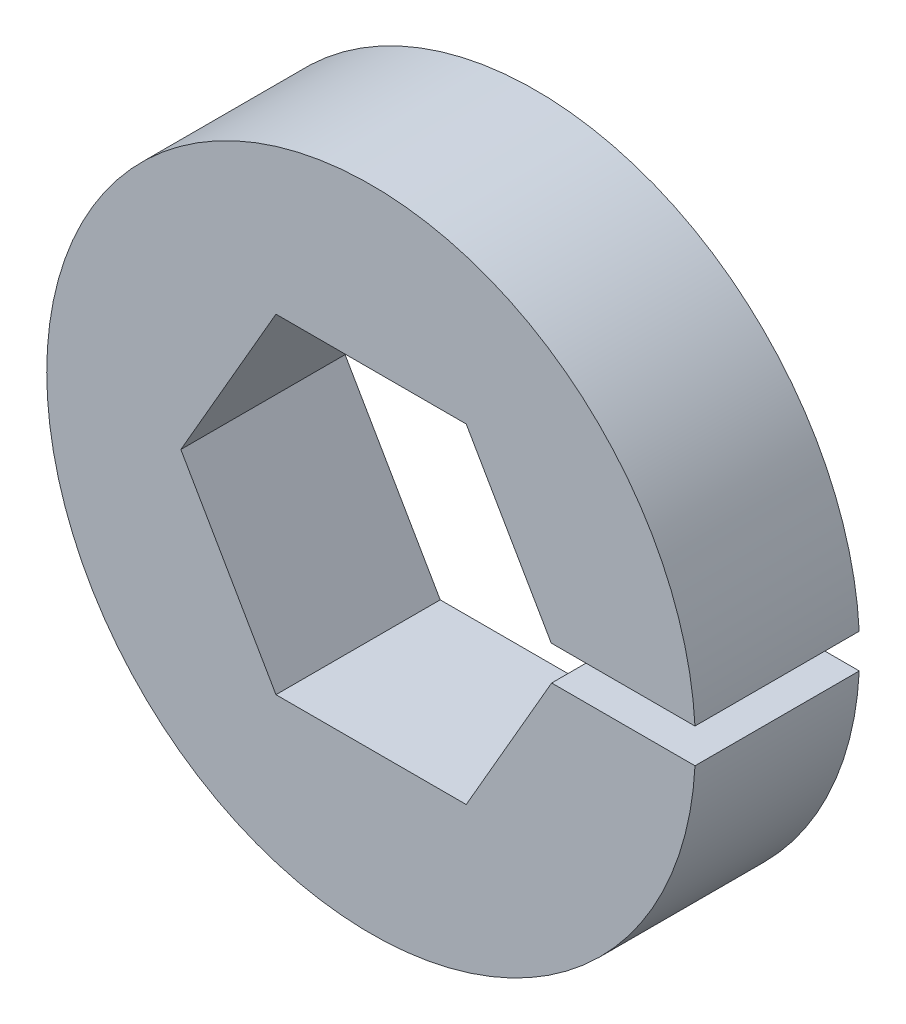
from build123d import *

# Parameters (mm, degrees)
SKETCH1_R           = 12.5
BOSS_EXTRUDE1_DEPTH = 6.33
SKETCH2_W           = 8.461167653
SKETCH2_H           = 1.32394958
CUT_EXTRUDE1_DEPTH  = 7.33


with BuildPart() as part:
    # Sketch1 → Boss-Extrude1 (new body)
    with BuildSketch(Plane.XY):
        Circle(SKETCH1_R)
        Polygon((7.332348419, 0), (3.666174209, 6.35), (-3.666174209, 6.35), (-7.332348419, 0), (-3.666174209, -6.35), (3.666174209, -6.35), align=None, mode=Mode.SUBTRACT)
    extrude(amount=BOSS_EXTRUDE1_DEPTH)

    # Sketch2 → Cut-Extrude1 (cut, through all)
    with BuildSketch(Plane.XY.offset(6.33)):
        with Locations((10.426813654, 0.014294586)):
            Rectangle(SKETCH2_W, SKETCH2_H)
    extrude(amount=-CUT_EXTRUDE1_DEPTH, mode=Mode.SUBTRACT)


solid = part.part
